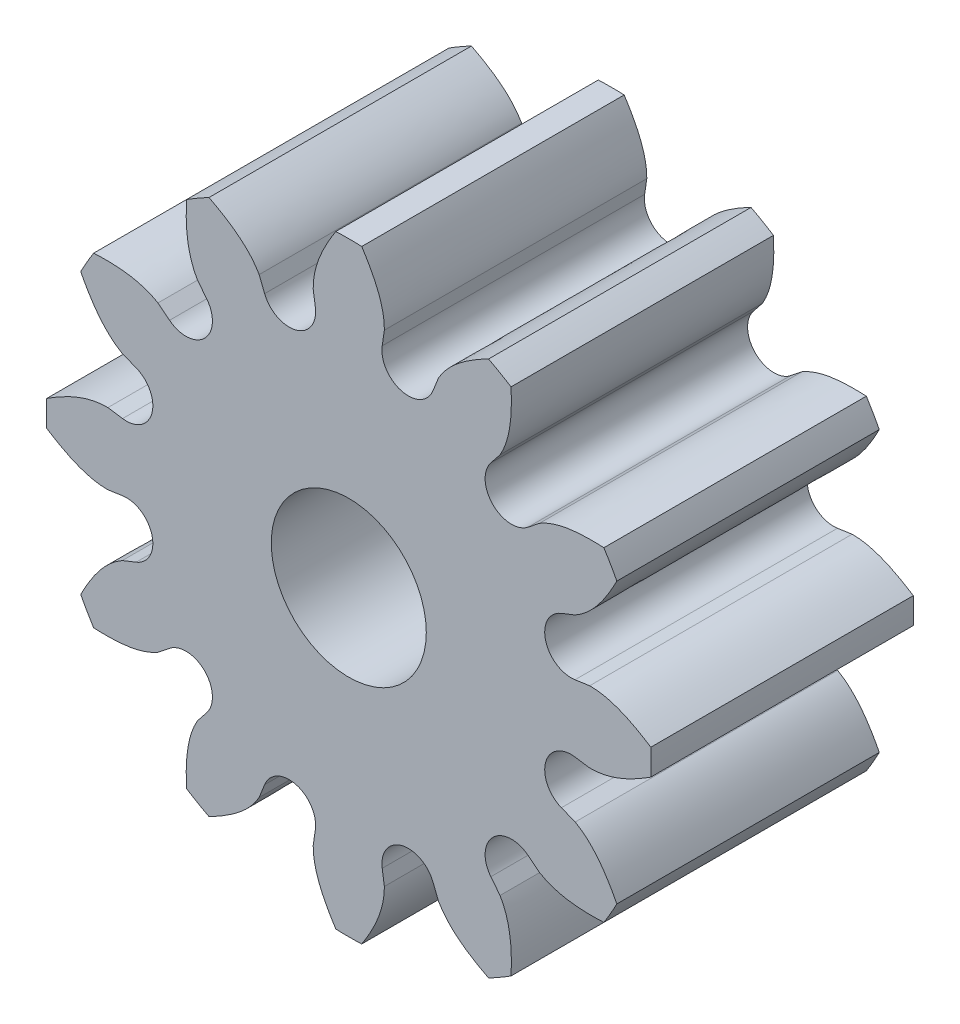
from build123d import *

# Parameters (mm, degrees)
SKETCH3_R                           = 2.3368
SKETCH3_R_2                         = 0.889
BASE_DEPTH                          = 3.0099
HALF_TOOTH_DEPTH                    = 3.0099
PATTERN_OF_HALF_TOOTH_COUNT         = 12
PATTERN_OF_HALF_TOOTH_COPY_1_DEPTH  = 3.0099
PATTERN_OF_HALF_TOOTH_COPY_2_DEPTH  = 3.0099
PATTERN_OF_HALF_TOOTH_COPY_3_DEPTH  = 3.0099
PATTERN_OF_HALF_TOOTH_COPY_4_DEPTH  = 3.0099
PATTERN_OF_HALF_TOOTH_COPY_5_DEPTH  = 3.0099
PATTERN_OF_HALF_TOOTH_COPY_6_DEPTH  = 3.0099
PATTERN_OF_HALF_TOOTH_COPY_7_DEPTH  = 3.0099
PATTERN_OF_HALF_TOOTH_COPY_8_DEPTH  = 3.0099
PATTERN_OF_HALF_TOOTH_COPY_9_DEPTH  = 3.0099
PATTERN_OF_HALF_TOOTH_COPY_10_DEPTH = 3.0099
PATTERN_OF_HALF_TOOTH_COPY_11_DEPTH = 3.0099


with BuildPart() as part:
    # Sketch3 → Base (new body)
    with BuildSketch(Plane.XY):
        Circle(SKETCH3_R)
        Circle(SKETCH3_R_2, mode=Mode.SUBTRACT)
    extrude(amount=BASE_DEPTH)

    # Sketch2 → Half tooth (add)
    with BuildSketch(Plane.XY):
        with BuildLine():
            Line((0, 3.4671), (0, 2.3368))
            ThreePointArc((0, 2.3368), (0.305013606, 2.316808352), (0.604808345, 2.257175471))
            ThreePointArc((0.604808345, 2.257175471), (0.429829858, 2.383610995), (0.383300567, 2.59441526))
            Line((0.383300567, 2.59441526), (0.408147008, 2.762591332))
            add(Edge.make_bspline(
                [(0.408147008, 2.762591332), (0.409130441, 2.824482126), (0.377383548, 3.076644936), (0.250049256, 3.305587472), (0.148558609, 3.463915812)],
                knots=[0, 0, 0, 0, 0.24444769, 1, 1, 1, 1], degree=3))
            ThreePointArc((0.148558609, 3.463915812), (0.074296365, 3.466303861), (0, 3.4671))
        make_face()
    half_tooth = extrude(amount=HALF_TOOTH_DEPTH)

    # Mirror of half tooth: Half tooth across plane
    add(half_tooth.mirror(Plane.ZY))

    # Pattern of half tooth: Half tooth ×12 about axis
    pattern_of_half_tooth_axis = Axis((0, 0, 3.0099), (0, 0, 1))
    for i in range(1, PATTERN_OF_HALF_TOOTH_COUNT):
        add(half_tooth.rotate(pattern_of_half_tooth_axis, i * 360 / PATTERN_OF_HALF_TOOTH_COUNT))

    # Pattern of half tooth copy 1 sketch → Pattern of half tooth copy 1 (add)
    with BuildSketch(Plane(origin=(0, 0, 0), x_dir=(-0.866025404, -0.5, 0), z_dir=(0, 0, 1))):
        with BuildLine():
            Line((0, -3.4671), (0, -2.3368))
            ThreePointArc((0, -2.3368), (0.305013606, -2.316808352), (0.604808345, -2.257175471))
            ThreePointArc((0.604808345, -2.257175471), (0.429829858, -2.383610995), (0.383300567, -2.59441526))
            Line((0.383300567, -2.59441526), (0.408147008, -2.762591332))
            add(Edge.make_bspline(
                [(0.408147008, -2.762591332), (0.409130441, -2.824482126), (0.377383548, -3.076644936), (0.250049256, -3.305587472), (0.148558609, -3.463915812)],
                knots=[0, 0, 0, 0, 0.24444769, 1, 1, 1, 1], degree=3))
            ThreePointArc((0.148558609, -3.463915812), (0.074296365, -3.466303861), (0, -3.4671))
        make_face()
    extrude(amount=PATTERN_OF_HALF_TOOTH_COPY_1_DEPTH)

    # Pattern of half tooth copy 2 sketch → Pattern of half tooth copy 2 (add)
    with BuildSketch(Plane(origin=(0, 0, 0), x_dir=(-0.5, -0.866025404, 0), z_dir=(0, 0, 1))):
        with BuildLine():
            Line((0, -3.4671), (0, -2.3368))
            ThreePointArc((0, -2.3368), (0.305013606, -2.316808352), (0.604808345, -2.257175471))
            ThreePointArc((0.604808345, -2.257175471), (0.429829858, -2.383610995), (0.383300567, -2.59441526))
            Line((0.383300567, -2.59441526), (0.408147008, -2.762591332))
            add(Edge.make_bspline(
                [(0.408147008, -2.762591332), (0.409130441, -2.824482126), (0.377383548, -3.076644936), (0.250049256, -3.305587472), (0.148558609, -3.463915812)],
                knots=[0, 0, 0, 0, 0.24444769, 1, 1, 1, 1], degree=3))
            ThreePointArc((0.148558609, -3.463915812), (0.074296365, -3.466303861), (0, -3.4671))
        make_face()
    extrude(amount=PATTERN_OF_HALF_TOOTH_COPY_2_DEPTH)

    # Pattern of half tooth copy 3 sketch → Pattern of half tooth copy 3 (add)
    with BuildSketch(Plane(origin=(0, 0, 0), x_dir=(0, -1, 0), z_dir=(0, 0, 1))):
        with BuildLine():
            Line((0, -3.4671), (0, -2.3368))
            ThreePointArc((0, -2.3368), (0.305013606, -2.316808352), (0.604808345, -2.257175471))
            ThreePointArc((0.604808345, -2.257175471), (0.429829858, -2.383610995), (0.383300567, -2.59441526))
            Line((0.383300567, -2.59441526), (0.408147008, -2.762591332))
            add(Edge.make_bspline(
                [(0.408147008, -2.762591332), (0.409130441, -2.824482126), (0.377383548, -3.076644936), (0.250049256, -3.305587472), (0.148558609, -3.463915812)],
                knots=[0, 0, 0, 0, 0.24444769, 1, 1, 1, 1], degree=3))
            ThreePointArc((0.148558609, -3.463915812), (0.074296365, -3.466303861), (0, -3.4671))
        make_face()
    extrude(amount=PATTERN_OF_HALF_TOOTH_COPY_3_DEPTH)

    # Pattern of half tooth copy 4 sketch → Pattern of half tooth copy 4 (add)
    with BuildSketch(Plane(origin=(0, 0, 0), x_dir=(0.5, -0.866025404, 0), z_dir=(0, 0, 1))):
        with BuildLine():
            Line((0, -3.4671), (0, -2.3368))
            ThreePointArc((0, -2.3368), (0.305013606, -2.316808352), (0.604808345, -2.257175471))
            ThreePointArc((0.604808345, -2.257175471), (0.429829858, -2.383610995), (0.383300567, -2.59441526))
            Line((0.383300567, -2.59441526), (0.408147008, -2.762591332))
            add(Edge.make_bspline(
                [(0.408147008, -2.762591332), (0.409130441, -2.824482126), (0.377383548, -3.076644936), (0.250049256, -3.305587472), (0.148558609, -3.463915812)],
                knots=[0, 0, 0, 0, 0.24444769, 1, 1, 1, 1], degree=3))
            ThreePointArc((0.148558609, -3.463915812), (0.074296365, -3.466303861), (0, -3.4671))
        make_face()
    extrude(amount=PATTERN_OF_HALF_TOOTH_COPY_4_DEPTH)

    # Pattern of half tooth copy 5 sketch → Pattern of half tooth copy 5 (add)
    with BuildSketch(Plane(origin=(0, 0, 0), x_dir=(0.866025404, -0.5, 0), z_dir=(0, 0, 1))):
        with BuildLine():
            Line((0, -3.4671), (0, -2.3368))
            ThreePointArc((0, -2.3368), (0.305013606, -2.316808352), (0.604808345, -2.257175471))
            ThreePointArc((0.604808345, -2.257175471), (0.429829858, -2.383610995), (0.383300567, -2.59441526))
            Line((0.383300567, -2.59441526), (0.408147008, -2.762591332))
            add(Edge.make_bspline(
                [(0.408147008, -2.762591332), (0.409130441, -2.824482126), (0.377383548, -3.076644936), (0.250049256, -3.305587472), (0.148558609, -3.463915812)],
                knots=[0, 0, 0, 0, 0.24444769, 1, 1, 1, 1], degree=3))
            ThreePointArc((0.148558609, -3.463915812), (0.074296365, -3.466303861), (0, -3.4671))
        make_face()
    extrude(amount=PATTERN_OF_HALF_TOOTH_COPY_5_DEPTH)

    # Pattern of half tooth copy 6 sketch → Pattern of half tooth copy 6 (add)
    with BuildSketch(Plane.XY):
        with BuildLine():
            Line((0, -3.4671), (0, -2.3368))
            ThreePointArc((0, -2.3368), (0.305013606, -2.316808352), (0.604808345, -2.257175471))
            ThreePointArc((0.604808345, -2.257175471), (0.429829858, -2.383610995), (0.383300567, -2.59441526))
            Line((0.383300567, -2.59441526), (0.408147008, -2.762591332))
            add(Edge.make_bspline(
                [(0.408147008, -2.762591332), (0.409130441, -2.824482126), (0.377383548, -3.076644936), (0.250049256, -3.305587472), (0.148558609, -3.463915812)],
                knots=[0, 0, 0, 0, 0.24444769, 1, 1, 1, 1], degree=3))
            ThreePointArc((0.148558609, -3.463915812), (0.074296365, -3.466303861), (0, -3.4671))
        make_face()
    extrude(amount=PATTERN_OF_HALF_TOOTH_COPY_6_DEPTH)

    # Pattern of half tooth copy 7 sketch → Pattern of half tooth copy 7 (add)
    with BuildSketch(Plane(origin=(0, 0, 0), x_dir=(0.866025404, 0.5, 0), z_dir=(0, 0, 1))):
        with BuildLine():
            Line((0, -3.4671), (0, -2.3368))
            ThreePointArc((0, -2.3368), (0.305013606, -2.316808352), (0.604808345, -2.257175471))
            ThreePointArc((0.604808345, -2.257175471), (0.429829858, -2.383610995), (0.383300567, -2.59441526))
            Line((0.383300567, -2.59441526), (0.408147008, -2.762591332))
            add(Edge.make_bspline(
                [(0.408147008, -2.762591332), (0.409130441, -2.824482126), (0.377383548, -3.076644936), (0.250049256, -3.305587472), (0.148558609, -3.463915812)],
                knots=[0, 0, 0, 0, 0.24444769, 1, 1, 1, 1], degree=3))
            ThreePointArc((0.148558609, -3.463915812), (0.074296365, -3.466303861), (0, -3.4671))
        make_face()
    extrude(amount=PATTERN_OF_HALF_TOOTH_COPY_7_DEPTH)

    # Pattern of half tooth copy 8 sketch → Pattern of half tooth copy 8 (add)
    with BuildSketch(Plane(origin=(0, 0, 0), x_dir=(0.5, 0.866025404, 0), z_dir=(0, 0, 1))):
        with BuildLine():
            Line((0, -3.4671), (0, -2.3368))
            ThreePointArc((0, -2.3368), (0.305013606, -2.316808352), (0.604808345, -2.257175471))
            ThreePointArc((0.604808345, -2.257175471), (0.429829858, -2.383610995), (0.383300567, -2.59441526))
            Line((0.383300567, -2.59441526), (0.408147008, -2.762591332))
            add(Edge.make_bspline(
                [(0.408147008, -2.762591332), (0.409130441, -2.824482126), (0.377383548, -3.076644936), (0.250049256, -3.305587472), (0.148558609, -3.463915812)],
                knots=[0, 0, 0, 0, 0.24444769, 1, 1, 1, 1], degree=3))
            ThreePointArc((0.148558609, -3.463915812), (0.074296365, -3.466303861), (0, -3.4671))
        make_face()
    extrude(amount=PATTERN_OF_HALF_TOOTH_COPY_8_DEPTH)

    # Pattern of half tooth copy 9 sketch → Pattern of half tooth copy 9 (add)
    with BuildSketch(Plane(origin=(0, 0, 0), x_dir=(0, 1, 0), z_dir=(0, 0, 1))):
        with BuildLine():
            Line((0, -3.4671), (0, -2.3368))
            ThreePointArc((0, -2.3368), (0.305013606, -2.316808352), (0.604808345, -2.257175471))
            ThreePointArc((0.604808345, -2.257175471), (0.429829858, -2.383610995), (0.383300567, -2.59441526))
            Line((0.383300567, -2.59441526), (0.408147008, -2.762591332))
            add(Edge.make_bspline(
                [(0.408147008, -2.762591332), (0.409130441, -2.824482126), (0.377383548, -3.076644936), (0.250049256, -3.305587472), (0.148558609, -3.463915812)],
                knots=[0, 0, 0, 0, 0.24444769, 1, 1, 1, 1], degree=3))
            ThreePointArc((0.148558609, -3.463915812), (0.074296365, -3.466303861), (0, -3.4671))
        make_face()
    extrude(amount=PATTERN_OF_HALF_TOOTH_COPY_9_DEPTH)

    # Pattern of half tooth copy 10 sketch → Pattern of half tooth copy 10 (add)
    with BuildSketch(Plane(origin=(0, 0, 0), x_dir=(-0.5, 0.866025404, 0), z_dir=(0, 0, 1))):
        with BuildLine():
            Line((0, -3.4671), (0, -2.3368))
            ThreePointArc((0, -2.3368), (0.305013606, -2.316808352), (0.604808345, -2.257175471))
            ThreePointArc((0.604808345, -2.257175471), (0.429829858, -2.383610995), (0.383300567, -2.59441526))
            Line((0.383300567, -2.59441526), (0.408147008, -2.762591332))
            add(Edge.make_bspline(
                [(0.408147008, -2.762591332), (0.409130441, -2.824482126), (0.377383548, -3.076644936), (0.250049256, -3.305587472), (0.148558609, -3.463915812)],
                knots=[0, 0, 0, 0, 0.24444769, 1, 1, 1, 1], degree=3))
            ThreePointArc((0.148558609, -3.463915812), (0.074296365, -3.466303861), (0, -3.4671))
        make_face()
    extrude(amount=PATTERN_OF_HALF_TOOTH_COPY_10_DEPTH)

    # Pattern of half tooth copy 11 sketch → Pattern of half tooth copy 11 (add)
    with BuildSketch(Plane(origin=(0, 0, 0), x_dir=(-0.866025404, 0.5, 0), z_dir=(0, 0, 1))):
        with BuildLine():
            Line((0, -3.4671), (0, -2.3368))
            ThreePointArc((0, -2.3368), (0.305013606, -2.316808352), (0.604808345, -2.257175471))
            ThreePointArc((0.604808345, -2.257175471), (0.429829858, -2.383610995), (0.383300567, -2.59441526))
            Line((0.383300567, -2.59441526), (0.408147008, -2.762591332))
            add(Edge.make_bspline(
                [(0.408147008, -2.762591332), (0.409130441, -2.824482126), (0.377383548, -3.076644936), (0.250049256, -3.305587472), (0.148558609, -3.463915812)],
                knots=[0, 0, 0, 0, 0.24444769, 1, 1, 1, 1], degree=3))
            ThreePointArc((0.148558609, -3.463915812), (0.074296365, -3.466303861), (0, -3.4671))
        make_face()
    extrude(amount=PATTERN_OF_HALF_TOOTH_COPY_11_DEPTH)


solid = part.part
